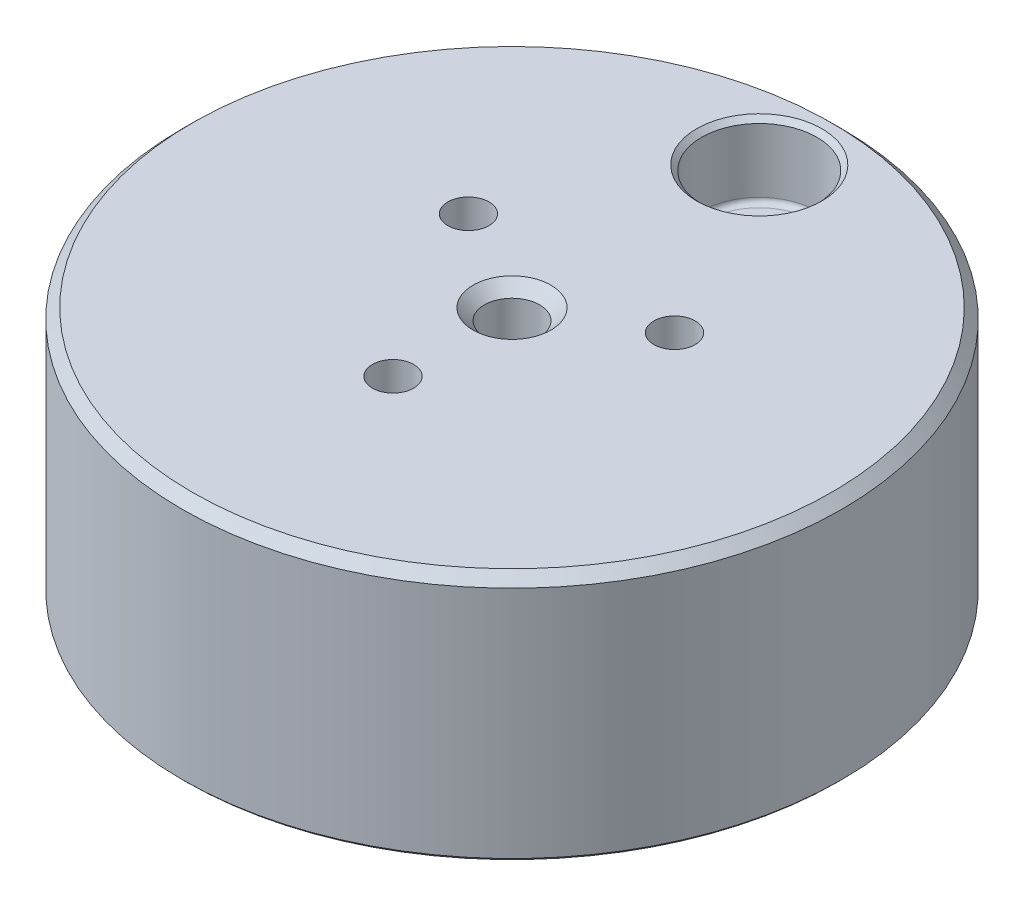
from build123d import *

# Parameters (mm, degrees)
M10X1_5_TAPPED_HOLE1_D           = 8.5
M10X1_5_TAPPED_HOLE1_DEPTH       = 24.4856
M10X1_5_TAPPED_HOLE1_CSINK_D     = 12
M10X1_5_TAPPED_HOLE1_CSINK_ANGLE = 90
M10X1_5_TAPPED_HOLE1_TIP         = 2.553657631
HOLE1_D                          = 6.35
HOLE1_DEPTH                      = 37.592
HOLE1_CBORE_D                    = 10.414
HOLE1_CBORE_DEPTH                = 6.35
HOLE1_TIP                        = 1.907732465
CHAMFER1_SIZE                    = 1.524
CHAMFER2_SIZE                    = 0.762
CHAMFER3_SIZE                    = 0.508
CHAMFER4_SIZE                    = 0.127
FILLET1_R                        = 0.8128


with BuildPart() as part:
    # Sketch1 → Revolve1 (revolve)
    with BuildSketch(Plane.XY, mode=Mode.PRIVATE) as revolve1_sk:
        Polygon((0, 0.508), (42.8625, 0.508), (43.3705, 0), (50.8, 0), (50.8, 38.1), (0, 38.1), align=None)
    revolve(revolve1_sk.sketch.rotate(Axis((0, 0, 0), (0, 1, 0)), 90), axis=Axis((0, 0, 0), (0, 1, 0)))  # turned: the seam where the file's is

    # Sketch2 → Cut-Revolve1 (revolve, cut)
    with BuildSketch(Plane(origin=(0, 0, 0), x_dir=(0, 0, -1), z_dir=(1, 0, 0))):
        Polygon((38.1, 38.1), (46.99, 38.1), (46.99, 26.67), (43.307, 26.67), (43.307, 0), (38.1, 0), align=None)
    revolve(axis=Axis((0, 38.1, -38.1), (0, 1, 0)), mode=Mode.SUBTRACT)

    # M10x1.5 Tapped Hole1
    with Locations(Plane(origin=(0, 38.1, 0), x_dir=(-1, 0, 0), z_dir=(0, 1, 0))):
        with Locations((0, 0)):
            CounterSinkHole(M10X1_5_TAPPED_HOLE1_D / 2, M10X1_5_TAPPED_HOLE1_CSINK_D / 2, depth=M10X1_5_TAPPED_HOLE1_DEPTH, counter_sink_angle=M10X1_5_TAPPED_HOLE1_CSINK_ANGLE)
            with Locations((0, 0, -(M10X1_5_TAPPED_HOLE1_DEPTH + M10X1_5_TAPPED_HOLE1_TIP / 2))):  # 118° drill point
                Cone(0, M10X1_5_TAPPED_HOLE1_D / 2, M10X1_5_TAPPED_HOLE1_TIP, mode=Mode.SUBTRACT)

    # Hole1
    with Locations(Plane.XZ.offset(-0.508)):
        with Locations((0, 18.330871047), (15.875, -9.165435523), (-15.875, -9.165435523)):
            CounterBoreHole(HOLE1_D / 2, HOLE1_CBORE_D / 2, HOLE1_CBORE_DEPTH, depth=HOLE1_DEPTH)
            with Locations((0, 0, -(HOLE1_DEPTH + HOLE1_TIP / 2))):  # 118° drill point
                Cone(0, HOLE1_D / 2, HOLE1_TIP, mode=Mode.SUBTRACT)

    # Chamfer1
    chamfer1_edges = [part.edges().sort_by_distance(p)[0] for p in [
        (0, 38.1, 50.8),
    ]]
    chamfer(chamfer1_edges, length=CHAMFER1_SIZE)

    # Chamfer2
    chamfer2_edges = [part.edges().sort_by_distance(p)[0] for p in [
        (0, 38.1, -29.21),
    ]]
    chamfer(chamfer2_edges, length=CHAMFER2_SIZE)

    # Chamfer3
    chamfer3_edges = [part.edges().sort_by_distance(p)[0] for p in [
        (0, 0, 50.8),
    ]]
    chamfer(chamfer3_edges, length=CHAMFER3_SIZE)

    # Chamfer4
    chamfer4_edges = [part.edges().sort_by_distance(p)[0] for p in [
        (-21.082, 0.508, -9.165435523),
        (10.668, 0.508, -9.165435523),
        (-5.207, 0.508, 18.330871047),
    ]]
    chamfer(chamfer4_edges, length=CHAMFER4_SIZE)

    # Fillet1
    fillet1_edges = [part.edges().sort_by_distance(p)[0] for p in [
        (0, 26.67, -29.21),
    ]]
    fillet(fillet1_edges, radius=FILLET1_R)


solid = part.part
